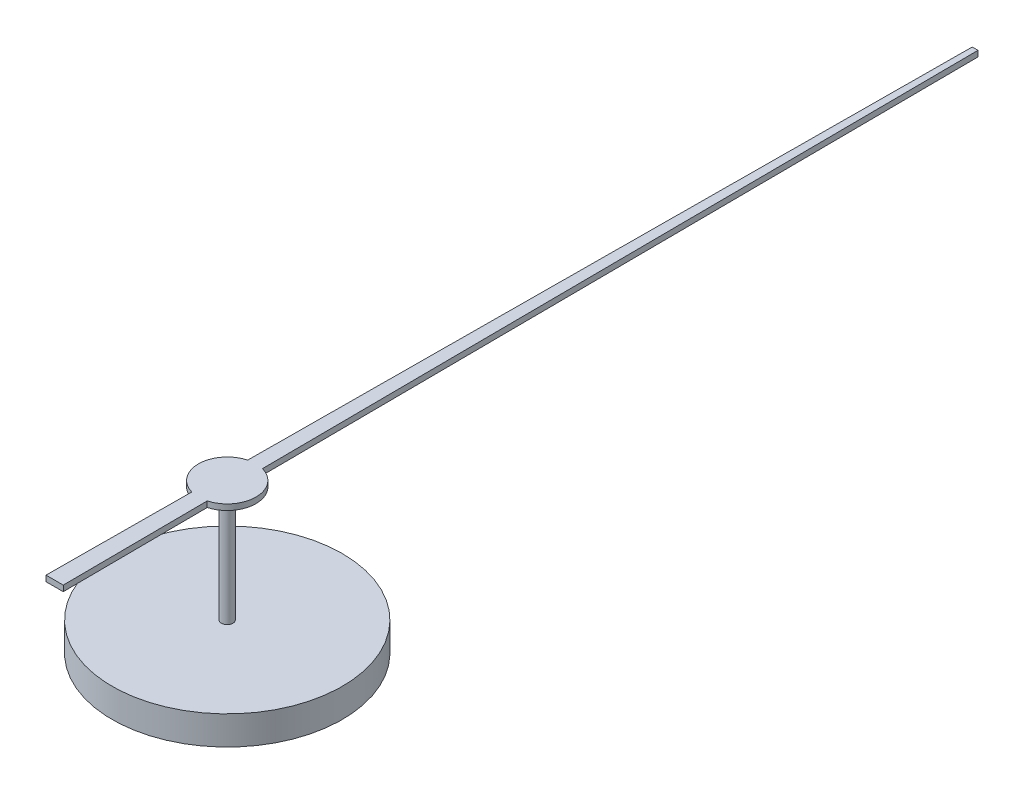
from build123d import *

# Parameters (mm, degrees)
BOSS_EXTRUDE1_DEPTH = 0.1
SKETCH2_R           = 0.1
BOSS_EXTRUDE2_DEPTH = 2
SKETCH3_R           = 2
BOSS_EXTRUDE3_DEPTH = 0.5


with BuildPart() as part:
    # Sketch1 → Boss-Extrude1 (new body)
    with BuildSketch(Plane(origin=(0, 0, 0), x_dir=(1, 0, 0), z_dir=(0, 1, 0))):
        with BuildLine():
            Line((-0.128229515, 0.483277551), (-0.05, 13))
            Line((-0.05, 13), (0.05, 13))
            Line((0.05, 13), (0.128229515, 0.483277551))
            ThreePointArc((0.128229515, 0.483277551), (0.499990235, 0.003124939), (0.134260231, -0.48163699))
            Line((0.134260231, -0.48163699), (0.15, -3))
            Line((0.15, -3), (-0.15, -3))
            Line((-0.15, -3), (-0.134260231, -0.48163699))
            ThreePointArc((-0.134260231, -0.48163699), (-0.499990235, 0.003124939), (-0.128229515, 0.483277551))
        make_face()
    extrude(amount=BOSS_EXTRUDE1_DEPTH)

    # Sketch2 → Boss-Extrude2 (add)
    with BuildSketch(Plane.XZ):
        Circle(SKETCH2_R)
    extrude(amount=BOSS_EXTRUDE2_DEPTH)

    # Sketch3 → Boss-Extrude3 (add)
    with BuildSketch(Plane.XZ.offset(2)):
        Circle(SKETCH3_R)
    extrude(amount=BOSS_EXTRUDE3_DEPTH)


solid = part.part
